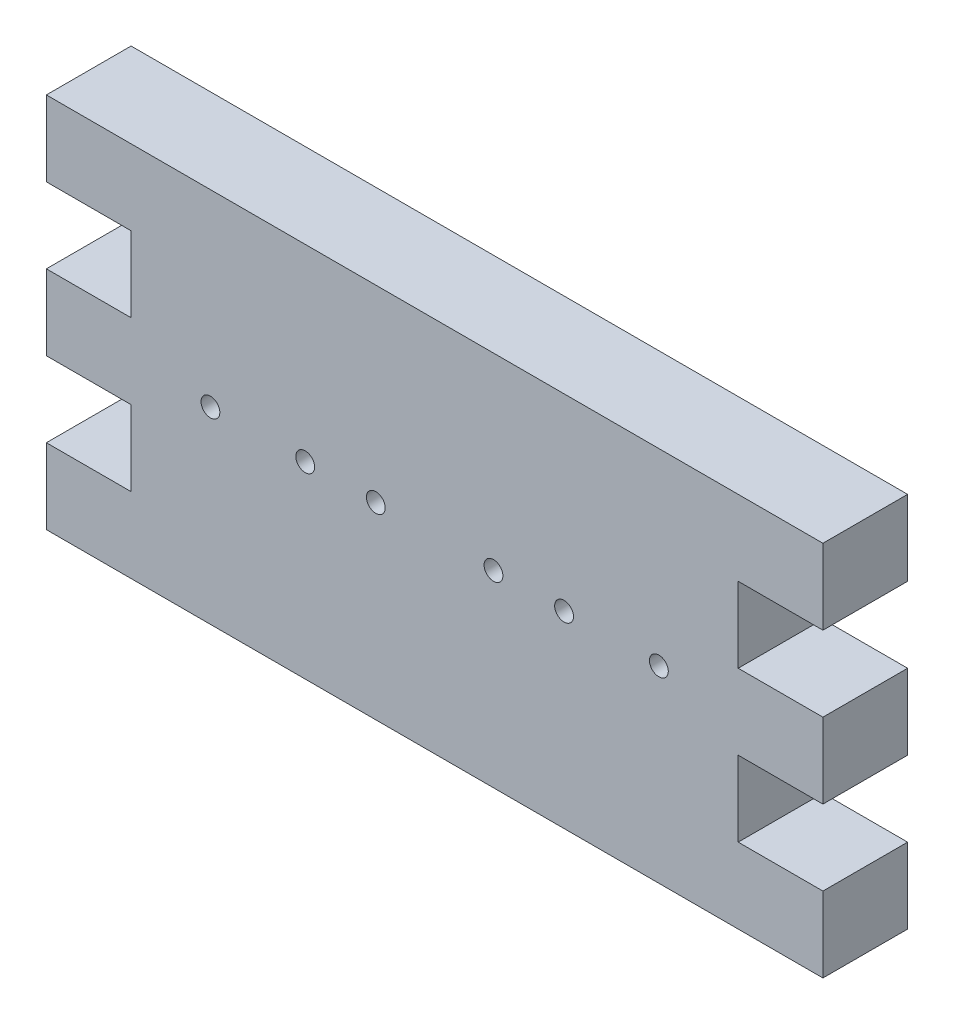
from build123d import *

# Parameters (mm, degrees)
SKETCH1_R           = 2
BOSS_EXTRUDE1_DEPTH = 18


with BuildPart() as part:
    # Sketch1 → Boss-Extrude1 (new body)
    with BuildSketch(Plane.XY):
        Polygon((-42.5, -50), (122.5, -50), (122.5, -34), (104.5, -34), (104.5, -18), (122.5, -18), (122.5, -2), (104.5, -2), (104.5, 14), (122.5, 14), (122.5, 30), (-42.5, 30), (-42.5, 14), (-24.5, 14), (-24.5, -2), (-42.5, -2), (-42.5, -18), (-24.5, -18), (-24.5, -34), (-42.5, -34), align=None)
        with Locations((-7.645719598, -10)):
            Circle(SKETCH1_R, mode=Mode.SUBTRACT)
        with Locations((12.5, -10)):
            Circle(SKETCH1_R, mode=Mode.SUBTRACT)
        with Locations((27.5, -10)):
            Circle(SKETCH1_R, mode=Mode.SUBTRACT)
        with Locations((52.5, -10)):
            Circle(SKETCH1_R, mode=Mode.SUBTRACT)
        with Locations((67.5, -10)):
            Circle(SKETCH1_R, mode=Mode.SUBTRACT)
        with Locations((87.645719598, -10)):
            Circle(SKETCH1_R, mode=Mode.SUBTRACT)
    extrude(amount=BOSS_EXTRUDE1_DEPTH)


solid = part.part
